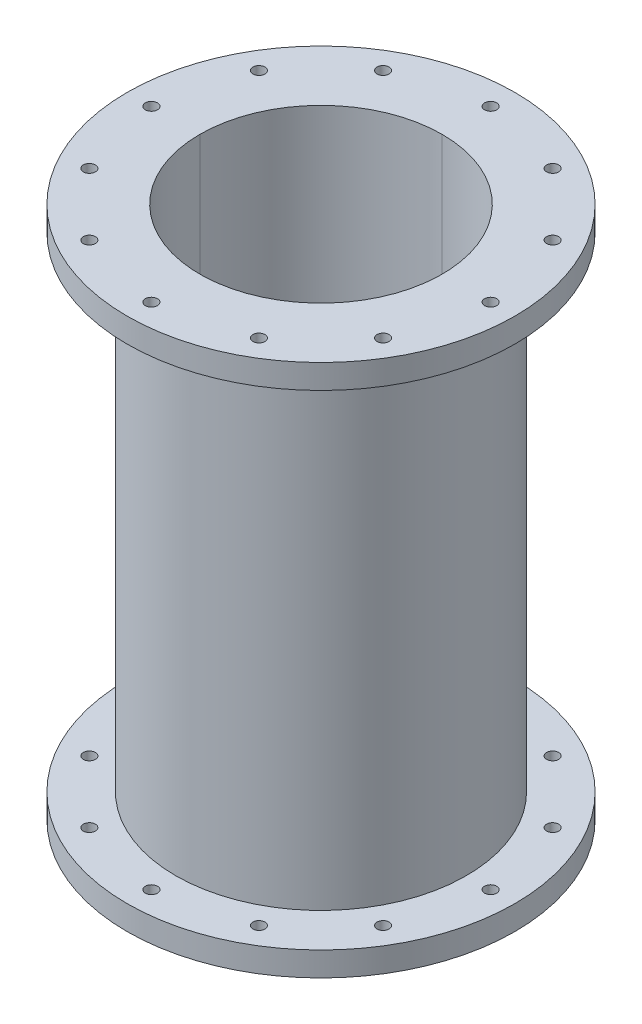
from build123d import *

# Parameters (mm, degrees)
SKETCH1_R           = 101.6
SKETCH1_R_2         = 63.5
SKETCH1_R_3         = 3.175
BOSS_EXTRUDE1_DEPTH = 139.7
SKETCH5_R           = 101.6
SKETCH5_R_2         = 3.175
SKETCH5_R_3         = 76.2
CUT_EXTRUDE3_DEPTH  = 127


with BuildPart() as part:
    # Sketch1 → Boss-Extrude1 (new body, symmetric)
    with BuildSketch(Plane(origin=(0, 0, 0), x_dir=(1, 0, 0), z_dir=(0, 1, 0))):
        Circle(SKETCH1_R)
        Circle(SKETCH1_R_2, mode=Mode.SUBTRACT)
        with Locations((0, 88.9)):
            Circle(SKETCH1_R_3, mode=Mode.SUBTRACT)
        with Locations((88.9, 0)):
            Circle(SKETCH1_R_3, mode=Mode.SUBTRACT)
        with Locations((44.45, 76.989658396)):
            Circle(SKETCH1_R_3, mode=Mode.SUBTRACT)
        with Locations((76.989658396, 44.45)):
            Circle(SKETCH1_R_3, mode=Mode.SUBTRACT)
        with Locations((76.989658396, -44.45)):
            Circle(SKETCH1_R_3, mode=Mode.SUBTRACT)
        with Locations((44.45, -76.989658396)):
            Circle(SKETCH1_R_3, mode=Mode.SUBTRACT)
        with Locations((0, -88.9)):
            Circle(SKETCH1_R_3, mode=Mode.SUBTRACT)
        with Locations((-44.45, -76.989658396)):
            Circle(SKETCH1_R_3, mode=Mode.SUBTRACT)
        with Locations((-76.989658396, -44.45)):
            Circle(SKETCH1_R_3, mode=Mode.SUBTRACT)
        with Locations((-88.9, 0)):
            Circle(SKETCH1_R_3, mode=Mode.SUBTRACT)
        with Locations((-76.989658396, 44.45)):
            Circle(SKETCH1_R_3, mode=Mode.SUBTRACT)
        with Locations((-44.45, 76.989658396)):
            Circle(SKETCH1_R_3, mode=Mode.SUBTRACT)
    extrude(amount=BOSS_EXTRUDE1_DEPTH, both=True)

    # Sketch5 → Cut-Extrude3 (cut, symmetric)
    with BuildSketch(Plane(origin=(0, 0, 0), x_dir=(1, 0, 0), z_dir=(0, 1, 0))):
        Circle(SKETCH5_R)
        with Locations((-44.45, 76.989658396)):
            Circle(SKETCH5_R_2, mode=Mode.SUBTRACT)
        with Locations((-88.9, 0)):
            Circle(SKETCH5_R_2, mode=Mode.SUBTRACT)
        with Locations((-76.989658396, -44.45)):
            Circle(SKETCH5_R_2, mode=Mode.SUBTRACT)
        with Locations((-44.45, -76.989658396)):
            Circle(SKETCH5_R_2, mode=Mode.SUBTRACT)
        with Locations((0, -88.9)):
            Circle(SKETCH5_R_2, mode=Mode.SUBTRACT)
        with Locations((44.45, -76.989658396)):
            Circle(SKETCH5_R_2, mode=Mode.SUBTRACT)
        with Locations((76.989658396, -44.45)):
            Circle(SKETCH5_R_2, mode=Mode.SUBTRACT)
        with Locations((88.9, 0)):
            Circle(SKETCH5_R_2, mode=Mode.SUBTRACT)
        with Locations((76.989658396, 44.45)):
            Circle(SKETCH5_R_2, mode=Mode.SUBTRACT)
        with Locations((44.45, 76.989658396)):
            Circle(SKETCH5_R_2, mode=Mode.SUBTRACT)
        with Locations((-76.989658396, 44.45)):
            Circle(SKETCH5_R_2, mode=Mode.SUBTRACT)
        with Locations((0, 88.9)):
            Circle(SKETCH5_R_2, mode=Mode.SUBTRACT)
        Circle(SKETCH5_R_3, mode=Mode.SUBTRACT)
    extrude(amount=CUT_EXTRUDE3_DEPTH, both=True, mode=Mode.SUBTRACT)


solid = part.part
